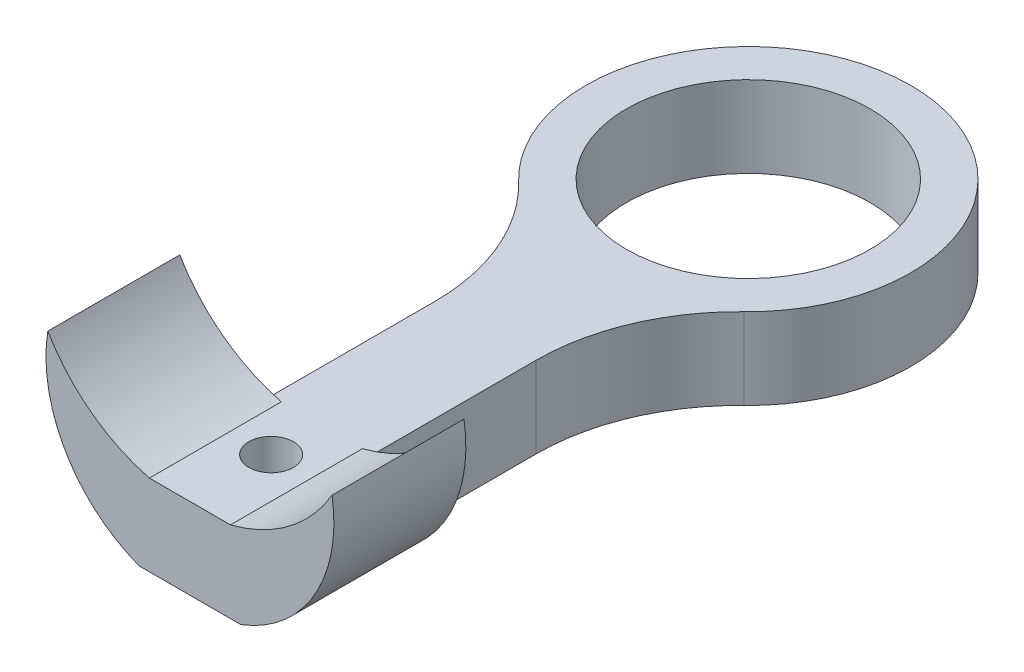
from build123d import *

# Parameters (mm, degrees)
SKETCH1_R           = 6
SKETCH1_R_2         = 1.1
BOSS_EXTRUDE1_DEPTH = 4
BOSS_EXTRUDE2_DEPTH = 6.5


with BuildPart() as part:
    # Sketch1 → Boss-Extrude1 (new body)
    with BuildSketch(Plane(origin=(0, 0, 0), x_dir=(1, 0, 0), z_dir=(0, 1, 0))):
        with BuildLine():
            Line((-2.5, -27.5), (2.5, -27.5))
            Line((2.5, -27.5), (2.5, -12.951833847))
            ThreePointArc((2.5, -12.951833847), (3.295532486, -9.043154047), (5.555555556, -5.756370599))
            ThreePointArc((5.555555556, -5.756370599), (0, 8), (-5.555555556, -5.756370599))
            ThreePointArc((-5.555555556, -5.756370599), (-3.295532486, -9.043154047), (-2.5, -12.951833847))
            Line((-2.5, -12.951833847), (-2.5, -27.5))
        make_face()
        Circle(SKETCH1_R, mode=Mode.SUBTRACT)
        with Locations((0, -23.5)):
            Circle(SKETCH1_R_2, mode=Mode.SUBTRACT)
    extrude(amount=BOSS_EXTRUDE1_DEPTH)

    # Sketch2 → Boss-Extrude2 (add)
    with BuildSketch(Plane.XY.offset(27.5)):
        with BuildLine():
            Line((-1.997835367, 4), (-2.5, 0))
            ThreePointArc((-2.5, 0), (-6.135441291, 3.080743774), (-7, 7.766888651))
            ThreePointArc((-7, 7.766888651), (-4.877255668, 5.381037947), (-1.997835367, 4))
        make_face()
    boss_extrude2 = extrude(amount=-BOSS_EXTRUDE2_DEPTH)

    # Mirror1: Boss-Extrude2 across plane
    add(boss_extrude2.mirror(Plane(origin=(0, 0, 0), x_dir=(0, 0, 1), z_dir=(1, 0, 0))))


solid = part.part
